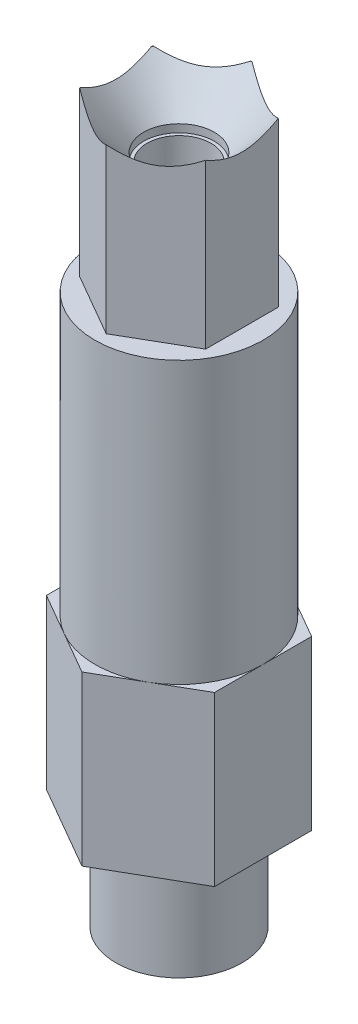
from build123d import *

# Parameters (mm, degrees)
BOSS_EXTRUDE1_DEPTH = 12.7
SKETCH2_R           = 4.7625
BOSS_EXTRUDE2_DEPTH = 7.62
SKETCH3_R           = 6.35
BOSS_EXTRUDE3_DEPTH = 33.528
CUT_EXTRUDE3_START  = -12.319
SKETCH8_R           = 6.35
CUT_EXTRUDE3_DEPTH  = 12.319
SKETCH9_R           = 2.667
CUT_EXTRUDE4_DEPTH  = 3.81


with BuildPart() as part:
    # Sketch1 → Boss-Extrude1 (new body)
    with BuildSketch(Plane(origin=(0, 0, 0), x_dir=(1, 0, 0), z_dir=(0, 1, 0))):
        Polygon((6.35, -3.666174209), (6.35, 3.666174209), (0, 7.332348419), (-6.35, 3.666174209), (-6.35, -3.666174209), (0, -7.332348419), align=None)
    extrude(amount=BOSS_EXTRUDE1_DEPTH)

    # Sketch2 → Boss-Extrude2 (add)
    with BuildSketch(Plane.XZ):
        Circle(SKETCH2_R)
    extrude(amount=BOSS_EXTRUDE2_DEPTH)

    # Sketch3 → Boss-Extrude3 (add)
    with BuildSketch(Plane(origin=(0, 12.7, 0), x_dir=(1, 0, 0), z_dir=(0, 1, 0))):
        Circle(SKETCH3_R)
    extrude(amount=BOSS_EXTRUDE3_DEPTH)

    # Sketch6 → Tapped Hole1 (revolve, cut)
    with BuildSketch(Plane(origin=(0, 46.228, 0), x_dir=(0, 0, 1), z_dir=(1, 0, 0))):
        Polygon((0, 0), (0, 20.263317848), (2.0193, 19.05), (2.0193, 16.002), (2.413, 16.002), (2.413, 3.506322905), (5.461, 0), align=None)
    revolve(axis=Axis((0, 52.578, 0), (0, -1, 0)), mode=Mode.SUBTRACT)

    # Sketch8 → Cut-Extrude3 (cut)
    with BuildSketch(Plane(origin=(0, 46.228, 0), x_dir=(1, 0, 0), z_dir=(0, 1, 0)).offset(CUT_EXTRUDE3_START)):
        Circle(SKETCH8_R)
        Polygon((-4.7625, -2.749630657), (0, -5.499261314), (4.7625, -2.749630657), (4.7625, 2.749630657), (0, 5.499261314), (-4.7625, 2.749630657), align=None, mode=Mode.SUBTRACT)
    extrude(amount=CUT_EXTRUDE3_DEPTH, mode=Mode.SUBTRACT)

    # Sketch9 → Cut-Extrude4 (cut)
    with BuildSketch(Plane(origin=(0, 46.228, 0), x_dir=(-1, 0, 0), z_dir=(0, -1, 0))):
        Circle(SKETCH9_R)
    extrude(amount=CUT_EXTRUDE4_DEPTH, mode=Mode.SUBTRACT)


solid = part.part
